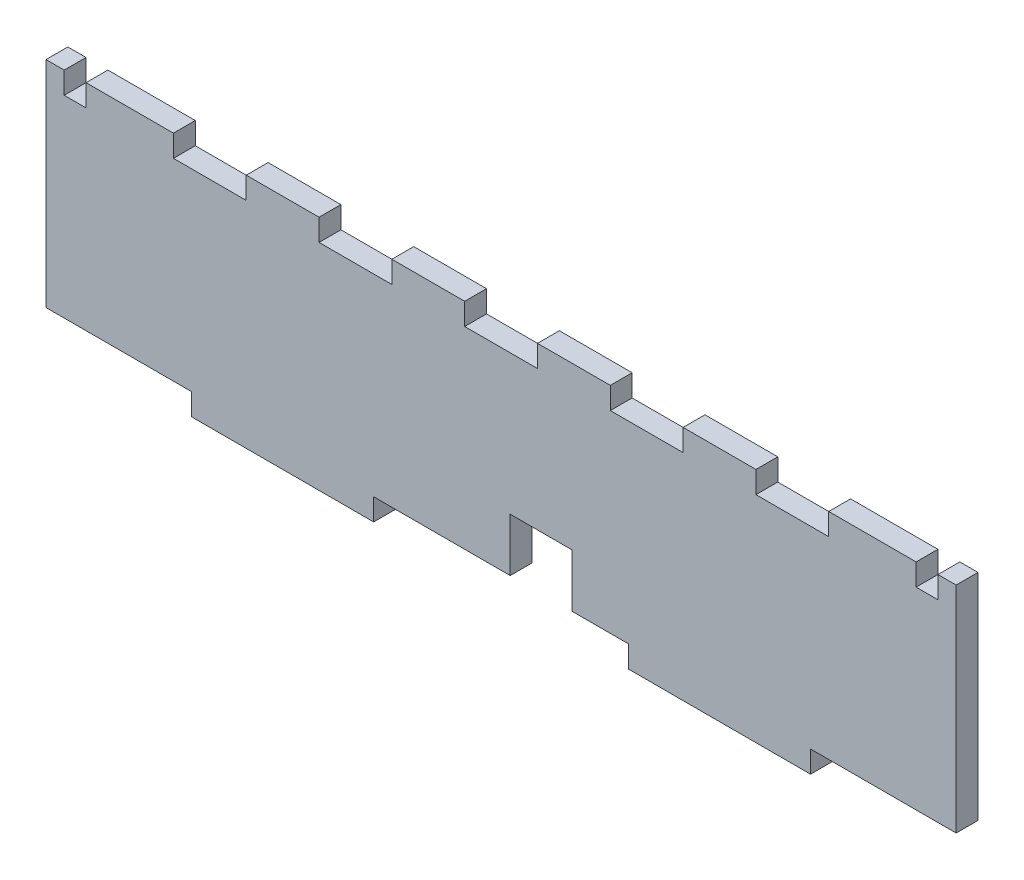
from build123d import *

# Parameters (mm, degrees)
BOSS_EXTRUDE1_DEPTH = 6
CUT_EXTRUDE1_REACH  = 8
SKETCH2_W           = 20
SKETCH2_H           = 6
SKETCH2_W_2         = 6
CUT_EXTRUDE2_REACH  = 8
SKETCH3_W           = 17
SKETCH3_H           = 15.5


with BuildPart() as part:
    # Sketch1 → Boss-Extrude1 (new body)
    with BuildSketch(Plane.XY):
        Polygon((-85, -26.5), (-85, -32.5), (-35, -32.5), (-35, -26.5), (35, -26.5), (35, -32.5), (85, -32.5), (85, -26.5), (125, -26.5), (125, 32.5), (-125, 32.5), (-125, -26.5), align=None)
    extrude(amount=BOSS_EXTRUDE1_DEPTH)

    # Sketch2 → Cut-Extrude1 (cut, up to next)
    with BuildSketch(Plane.XY.offset(6), mode=Mode.PRIVATE) as cut_extrude1_sk1:
        with Locations((-80, 29.5)):
            Rectangle(SKETCH2_W, SKETCH2_H)
    cut_extrude1_tool1 = extrude(cut_extrude1_sk1.sketch, amount=-CUT_EXTRUDE1_REACH, mode=Mode.PRIVATE) & part.part
    add(cut_extrude1_tool1.solids().sort_by_distance((-80, 29.5, 6))[0], mode=Mode.SUBTRACT)
    # Sketch2 → Cut-Extrude1 (cut, up to next)
    with BuildSketch(Plane.XY.offset(6), mode=Mode.PRIVATE) as cut_extrude1_sk2:
        with Locations((-40, 29.5)):
            Rectangle(SKETCH2_W, SKETCH2_H)
    cut_extrude1_tool2 = extrude(cut_extrude1_sk2.sketch, amount=-CUT_EXTRUDE1_REACH, mode=Mode.PRIVATE) & part.part
    add(cut_extrude1_tool2.solids().sort_by_distance((-40, 29.5, 6))[0], mode=Mode.SUBTRACT)
    # Sketch2 → Cut-Extrude1 (cut, up to next)
    with BuildSketch(Plane.XY.offset(6), mode=Mode.PRIVATE) as cut_extrude1_sk3:
        with Locations((0, 29.5)):
            Rectangle(SKETCH2_W, SKETCH2_H)
    cut_extrude1_tool3 = extrude(cut_extrude1_sk3.sketch, amount=-CUT_EXTRUDE1_REACH, mode=Mode.PRIVATE) & part.part
    add(cut_extrude1_tool3.solids().sort_by_distance((0, 29.5, 6))[0], mode=Mode.SUBTRACT)
    # Sketch2 → Cut-Extrude1 (cut, up to next)
    with BuildSketch(Plane.XY.offset(6), mode=Mode.PRIVATE) as cut_extrude1_sk4:
        with Locations((40, 29.5)):
            Rectangle(SKETCH2_W, SKETCH2_H)
    cut_extrude1_tool4 = extrude(cut_extrude1_sk4.sketch, amount=-CUT_EXTRUDE1_REACH, mode=Mode.PRIVATE) & part.part
    add(cut_extrude1_tool4.solids().sort_by_distance((40, 29.5, 6))[0], mode=Mode.SUBTRACT)
    # Sketch2 → Cut-Extrude1 (cut, up to next)
    with BuildSketch(Plane.XY.offset(6), mode=Mode.PRIVATE) as cut_extrude1_sk5:
        with Locations((80, 29.5)):
            Rectangle(SKETCH2_W, SKETCH2_H)
    cut_extrude1_tool5 = extrude(cut_extrude1_sk5.sketch, amount=-CUT_EXTRUDE1_REACH, mode=Mode.PRIVATE) & part.part
    add(cut_extrude1_tool5.solids().sort_by_distance((80, 29.5, 6))[0], mode=Mode.SUBTRACT)
    # Sketch2 → Cut-Extrude1 (cut, up to next)
    with BuildSketch(Plane.XY.offset(6), mode=Mode.PRIVATE) as cut_extrude1_sk6:
        with Locations((-117, 29.5)):
            Rectangle(SKETCH2_W_2, SKETCH2_H)
    cut_extrude1_tool6 = extrude(cut_extrude1_sk6.sketch, amount=-CUT_EXTRUDE1_REACH, mode=Mode.PRIVATE) & part.part
    add(cut_extrude1_tool6.solids().sort_by_distance((-117, 29.5, 6))[0], mode=Mode.SUBTRACT)
    # Sketch2 → Cut-Extrude1 (cut, up to next)
    with BuildSketch(Plane.XY.offset(6), mode=Mode.PRIVATE) as cut_extrude1_sk7:
        with Locations((117, 29.5)):
            Rectangle(SKETCH2_W_2, SKETCH2_H)
    cut_extrude1_tool7 = extrude(cut_extrude1_sk7.sketch, amount=-CUT_EXTRUDE1_REACH, mode=Mode.PRIVATE) & part.part
    add(cut_extrude1_tool7.solids().sort_by_distance((117, 29.5, 6))[0], mode=Mode.SUBTRACT)

    # Sketch3 → Cut-Extrude2 (cut, up to next)
    with BuildSketch(Plane(origin=(0, 0, 0), x_dir=(-1, 0, 0), z_dir=(0, 0, -1)), mode=Mode.PRIVATE) as cut_extrude2_sk1:
        with Locations((-11.006971283, -19.65)):
            Rectangle(SKETCH3_W, SKETCH3_H)
    cut_extrude2_tool1 = extrude(cut_extrude2_sk1.sketch, amount=-CUT_EXTRUDE2_REACH, mode=Mode.PRIVATE) & part.part
    add(cut_extrude2_tool1.solids().sort_by_distance((11.006971, -19.65, 0))[0], mode=Mode.SUBTRACT)


solid = part.part
